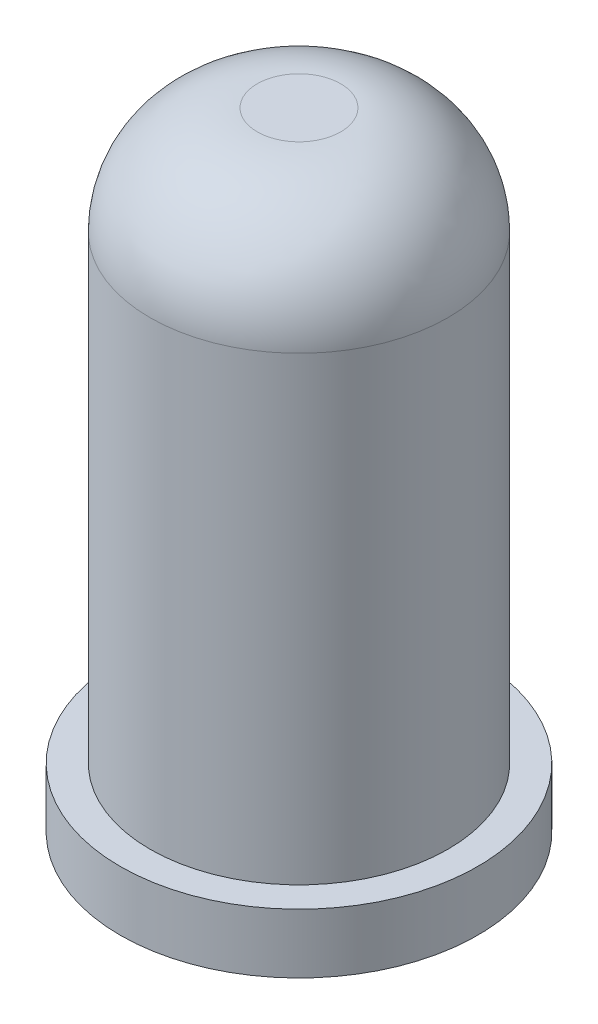
from build123d import *

# Parameters (mm, degrees)
SKETCH1_R           = 2.5
BOSS_EXTRUDE1_DEPTH = 9.525
SKETCH2_R           = 3
BOSS_EXTRUDE2_DEPTH = 1
FILLET1_R           = 1.8


with BuildPart() as part:
    # Sketch1 → Boss-Extrude1 (new body)
    with BuildSketch(Plane(origin=(0, 0, 0), x_dir=(1, 0, 0), z_dir=(0, 1, 0))):
        Circle(SKETCH1_R)
    extrude(amount=BOSS_EXTRUDE1_DEPTH)

    # Sketch2 → Boss-Extrude2 (add)
    with BuildSketch(Plane.XZ):
        Circle(SKETCH2_R)
    extrude(amount=BOSS_EXTRUDE2_DEPTH)

    # Fillet1
    fillet1_edges = [part.edges().sort_by_distance(p)[0] for p in [
        (-2.5, 9.525, 0),
    ]]
    fillet(fillet1_edges, radius=FILLET1_R)


solid = part.part
